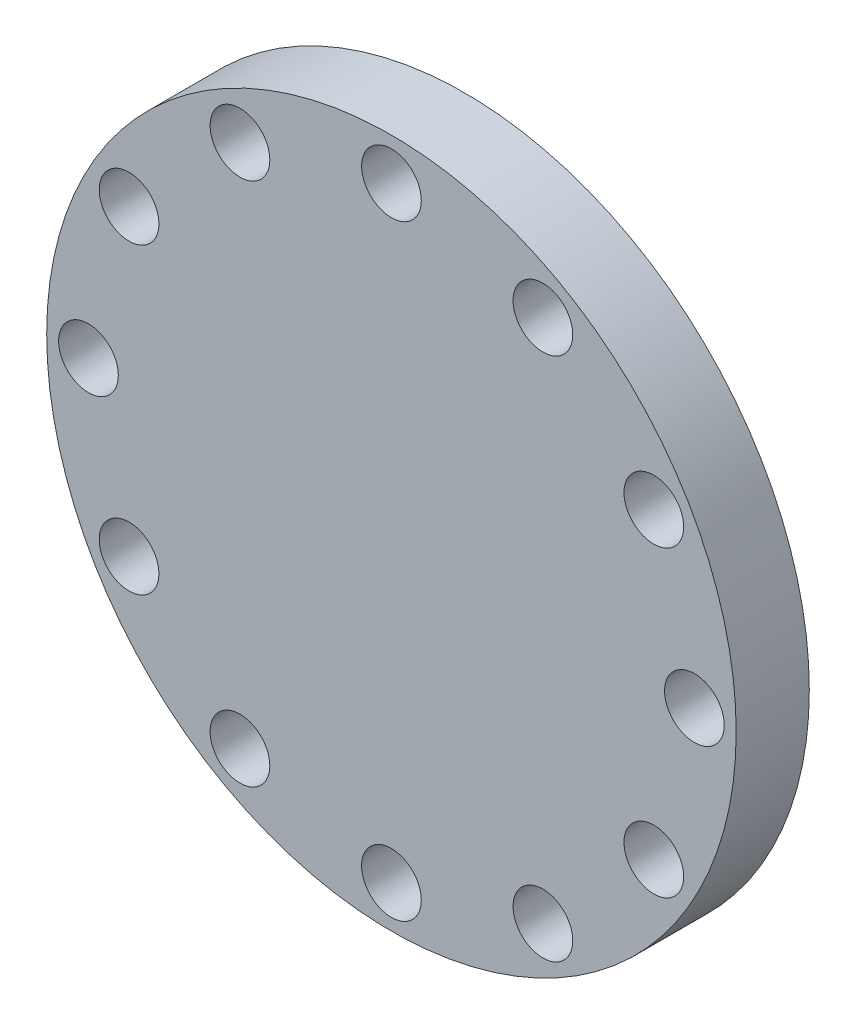
from build123d import *

# Parameters (mm, degrees)
SKETCH1_R           = 330
SKETCH1_R_2         = 247.5
BOSS_EXTRUDE1_DEPTH = 70
SKETCH2_R           = 28.575
CUT_EXTRUDE1_DEPTH  = 131


with BuildPart() as part:
    # Sketch1 → Boss-Extrude1 (new body)
    with BuildSketch(Plane.XY):
        Circle(SKETCH1_R)
        Circle(SKETCH1_R_2, mode=Mode.SUBTRACT)
        Circle(SKETCH1_R_2)
    extrude(amount=BOSS_EXTRUDE1_DEPTH)

    # Sketch2 → Cut-Extrude1 (cut)
    with BuildSketch(Plane.XY):
        with Locations((0, 290)):
            Circle(SKETCH2_R)
        with Locations((145, 251.147367097)):
            Circle(SKETCH2_R)
        with Locations((251.147367097, 145)):
            Circle(SKETCH2_R)
        with Locations((290, 0)):
            Circle(SKETCH2_R)
        with Locations((251.147367098, -145)):
            Circle(SKETCH2_R)
        with Locations((145, -251.147367097)):
            Circle(SKETCH2_R)
        with Locations((0, -290)):
            Circle(SKETCH2_R)
        with Locations((-145, -251.147367097)):
            Circle(SKETCH2_R)
        with Locations((-251.147367097, -145)):
            Circle(SKETCH2_R)
        with Locations((-290, 0)):
            Circle(SKETCH2_R)
        with Locations((-251.147367097, 145)):
            Circle(SKETCH2_R)
        with Locations((-145, 251.147367097)):
            Circle(SKETCH2_R)
    extrude(amount=CUT_EXTRUDE1_DEPTH, mode=Mode.SUBTRACT)


solid = part.part
